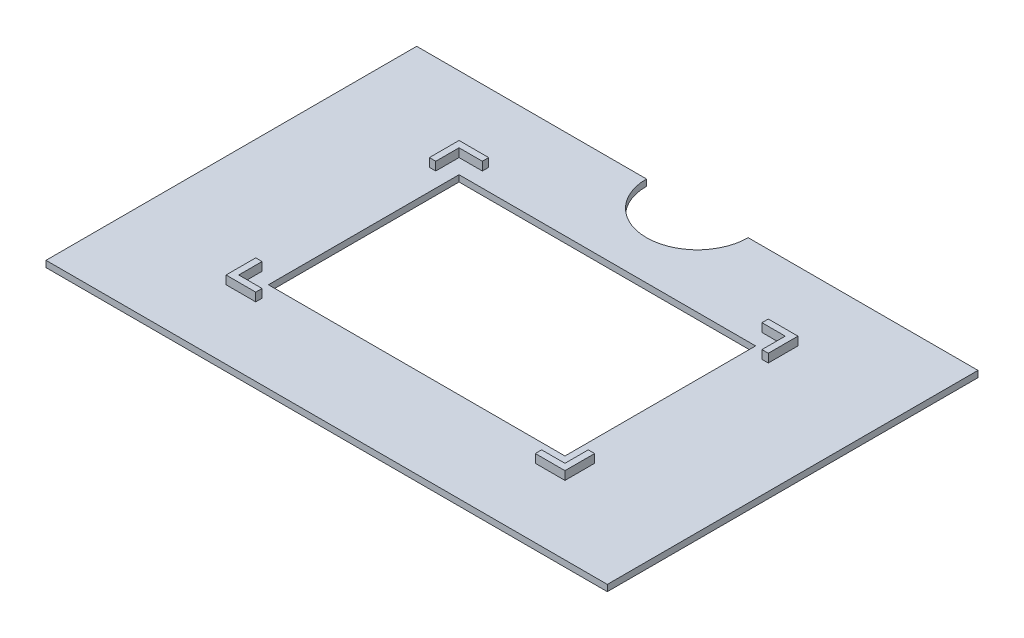
from build123d import *

# Parameters (mm, degrees)
SKETCH1_W           = 132.5
SKETCH1_H           = 87.5
BOSS_EXTRUDE1_DEPTH = 1.5
SKETCH2_W           = 80
SKETCH2_H           = 55
BOSS_EXTRUDE2_DEPTH = 2
SKETCH3_W           = 77
SKETCH3_H           = 52
CUT_EXTRUDE1_DEPTH  = 2
CUT_EXTRUDE2_REACH  = 3.5
SKETCH4_W           = 70
SKETCH4_H           = 45
SKETCH5_W           = 1.5
SKETCH5_H           = 41
SKETCH5_W_2         = 66
SKETCH5_H_2         = 1.5
CUT_EXTRUDE3_DEPTH  = 2
CUT_EXTRUDE4_DEPTH  = 1.5


with BuildPart() as part:
    # Sketch1 → Boss-Extrude1 (new body)
    with BuildSketch(Plane(origin=(0, 0, 0), x_dir=(1, 0, 0), z_dir=(0, 1, 0))):
        Rectangle(SKETCH1_W, SKETCH1_H)
    extrude(amount=BOSS_EXTRUDE1_DEPTH)

    # Sketch2 → Boss-Extrude2 (add)
    with BuildSketch(Plane(origin=(0, 1.5, 0), x_dir=(1, 0, 0), z_dir=(0, 1, 0))):
        Rectangle(SKETCH2_W, SKETCH2_H)
    extrude(amount=BOSS_EXTRUDE2_DEPTH)

    # Sketch3 → Cut-Extrude1 (cut)
    with BuildSketch(Plane(origin=(0, 3.5, 0), x_dir=(1, 0, 0), z_dir=(0, 1, 0))):
        Rectangle(SKETCH3_W, SKETCH3_H)
    extrude(amount=-CUT_EXTRUDE1_DEPTH, mode=Mode.SUBTRACT)

    # Sketch4 → Cut-Extrude2 (cut, up to next)
    with BuildSketch(Plane(origin=(0, 1.5, 0), x_dir=(1, 0, 0), z_dir=(0, 1, 0)), mode=Mode.PRIVATE) as cut_extrude2_sk1:
        Rectangle(SKETCH4_W, SKETCH4_H)
    cut_extrude2_tool1 = extrude(cut_extrude2_sk1.sketch, amount=-CUT_EXTRUDE2_REACH, mode=Mode.PRIVATE) & part.part
    add(cut_extrude2_tool1.solids().sort_by_distance((0, 1.5, 0))[0], mode=Mode.SUBTRACT)

    # Sketch5 → Cut-Extrude3 (cut)
    with BuildSketch(Plane(origin=(0, 3.5, 0), x_dir=(1, 0, 0), z_dir=(0, 1, 0))):
        with Locations((-39.25, 0)):
            Rectangle(SKETCH5_W, SKETCH5_H)
        with Locations((39.25, 0)):
            Rectangle(SKETCH5_W, SKETCH5_H)
        with Locations((0, 26.75)):
            Rectangle(SKETCH5_W_2, SKETCH5_H_2)
        with Locations((0, -26.75)):
            Rectangle(SKETCH5_W_2, SKETCH5_H_2)
    extrude(amount=-CUT_EXTRUDE3_DEPTH, mode=Mode.SUBTRACT)

    # Sketch6 → Cut-Extrude4 (cut)
    with BuildSketch(Plane(origin=(0, 1.5, 0), x_dir=(1, 0, 0), z_dir=(0, 1, 0))):
        with BuildLine():
            Line((-12, 43.75), (12, 43.75))
            ThreePointArc((12, 43.75), (0, 31.75), (-12, 43.75))
        make_face()
    extrude(amount=-CUT_EXTRUDE4_DEPTH, mode=Mode.SUBTRACT)


solid = part.part
